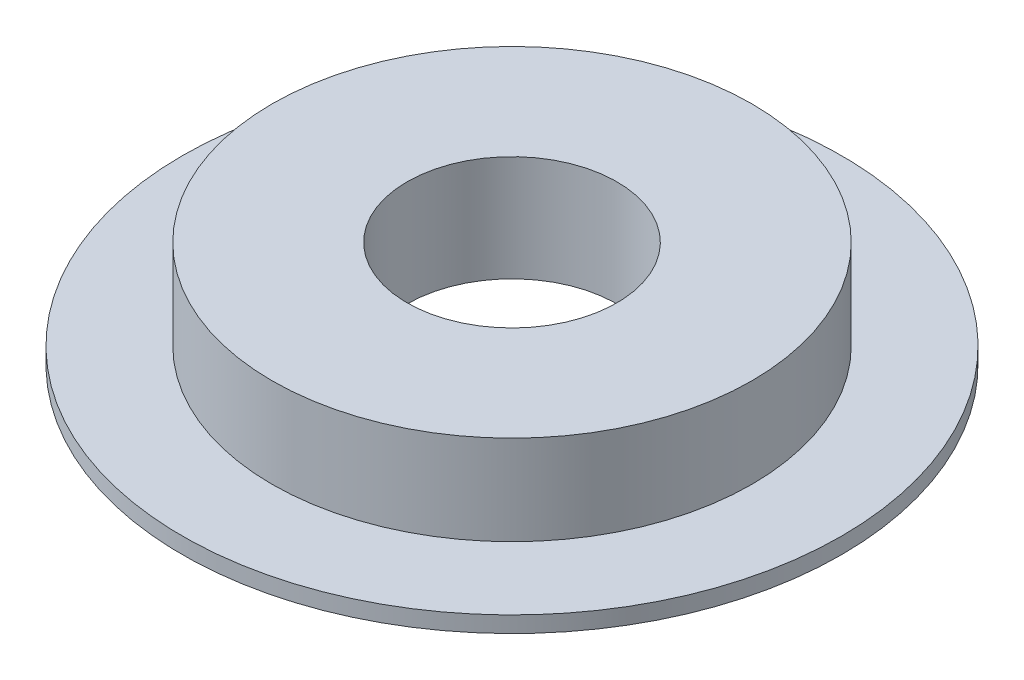
from build123d import *


with BuildPart() as part:
    # Croquis1 → Revolución1 (revolve)
    with BuildSketch(Plane.XY):
        Polygon((-40.97158728, 8.972889318), (-40.97158728, -2.827110682), (-66.02158728, -2.827110682), (-66.02158728, -1.027110682), (-56.02158728, -1.027110682), (-56.02158728, 8.972889318), align=None)
    revolve(axis=Axis((-29.27158728, 13.972889318, 0), (0, -1, 0)))


solid = part.part
